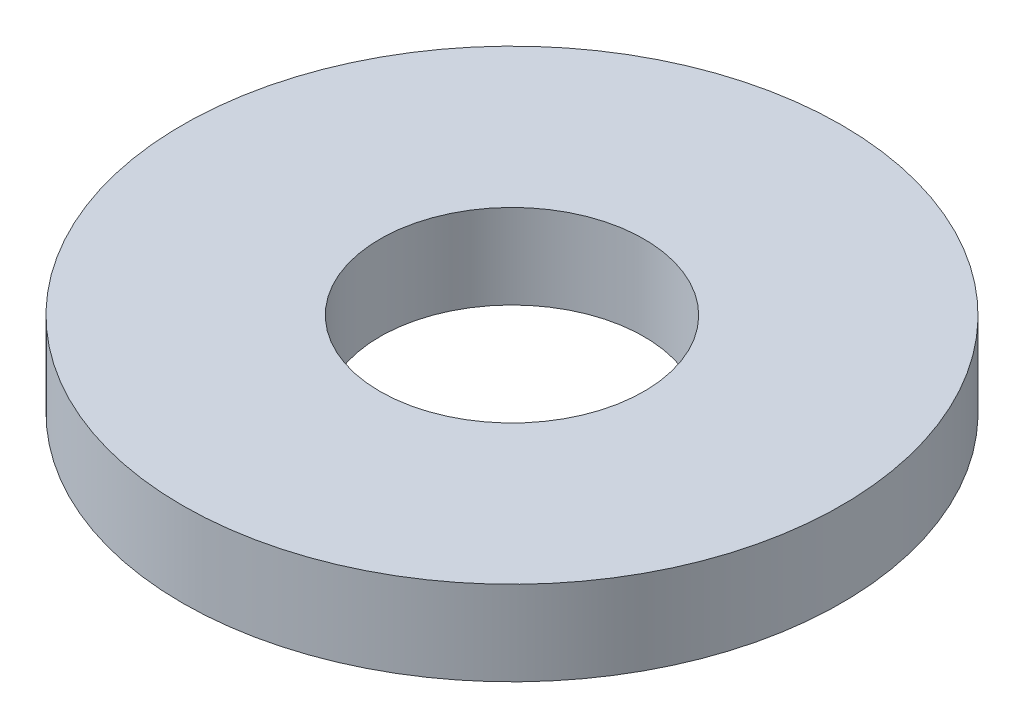
from build123d import *

# Parameters (mm, degrees)
SKETCH1_R           = 3.9624
BOSS_EXTRUDE1_DEPTH = 1.016
SKETCH5_R           = 1.5875
CUT_EXTRUDE1_DEPTH  = 2.016


with BuildPart() as part:
    # Sketch1 → Boss-Extrude1 (new body)
    with BuildSketch(Plane(origin=(0, 0, 0), x_dir=(1, 0, 0), z_dir=(0, 1, 0))):
        Circle(SKETCH1_R)
    extrude(amount=BOSS_EXTRUDE1_DEPTH)

    # Sketch5 → Cut-Extrude1 (cut, through all)
    with BuildSketch(Plane(origin=(0, 1.016, 0), x_dir=(-1, 0, 0), z_dir=(0, 1, 0))):
        Circle(SKETCH5_R)
    extrude(amount=-CUT_EXTRUDE1_DEPTH, mode=Mode.SUBTRACT)


solid = part.part
